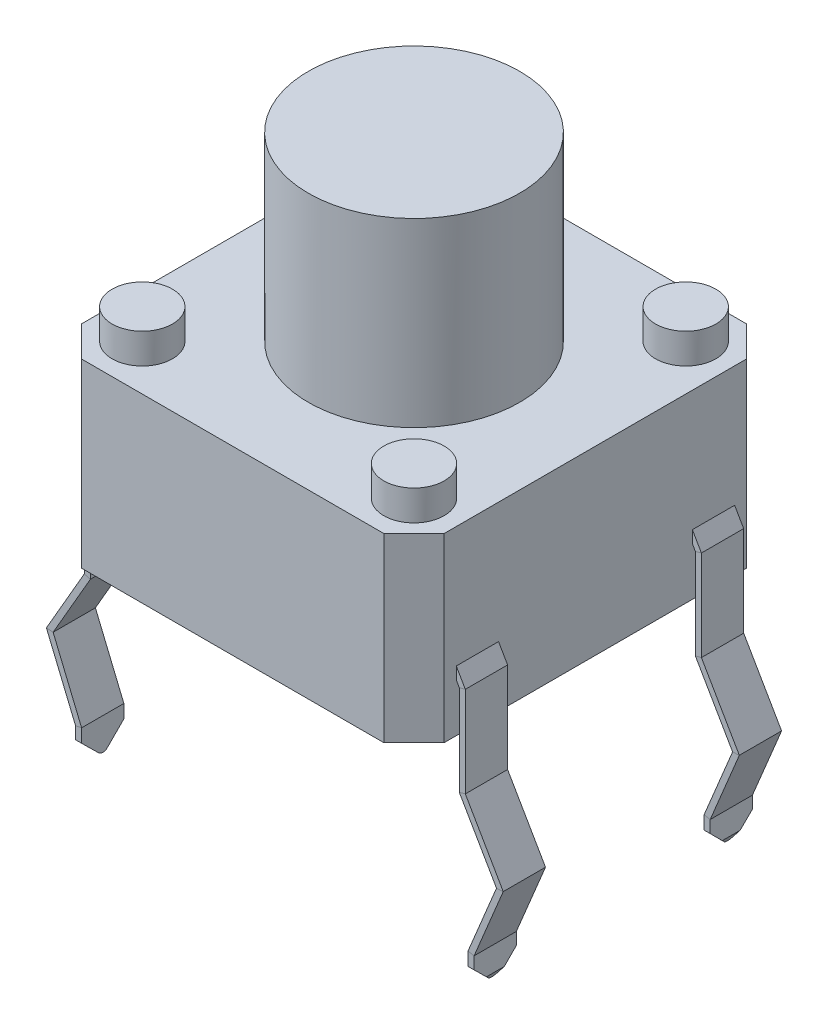
from build123d import *

# Parameters (mm, degrees)
SKETCH1_W               = 6.01
SKETCH1_H               = 6.01
BOSS_EXTRUDE1_DEPTH     = 3
CHAMFER1_SIZE           = 0.5
SKETCH3_R               = 1.75
BOSS_EXTRUDE2_DEPTH     = 3
SKETCH4_R               = 0.5
BOSS_EXTRUDE6_DEPTH     = 0.5
SKETCH5_R               = 0.5
BOSS_EXTRUDE7_DEPTH     = 0.5
SKETCH6_W               = 0.7
SKETCH6_H               = 0.2
MIRROR2_COPY_1_SKETCH_W = 0.7
MIRROR2_COPY_1_SKETCH_H = 0.2
CUT_EXTRUDE1_DEPTH      = 4.782799277


with BuildPart() as part:
    # Sketch1 → Boss-Extrude1 (new body)
    with BuildSketch(Plane(origin=(0, 0, 0), x_dir=(1, 0, 0), z_dir=(0, 1, 0))):
        Rectangle(SKETCH1_W, SKETCH1_H)
    extrude(amount=BOSS_EXTRUDE1_DEPTH)

    # Chamfer1
    chamfer1_edges = [part.edges().sort_by_distance(p)[0] for p in [
        (3.005, 1.5, 3.005),
        (-3.005, 1.5, 3.005),
        (-3.005, 1.5, -3.005),
        (3.005, 1.5, -3.005),
    ]]
    chamfer(chamfer1_edges, length=CHAMFER1_SIZE)

    # Sketch3 → Boss-Extrude2 (add)
    with BuildSketch(Plane(origin=(0, 3, 0), x_dir=(1, 0, 0), z_dir=(0, 1, 0))):
        Circle(SKETCH3_R)
    extrude(amount=BOSS_EXTRUDE2_DEPTH)

    # Sketch4 → Boss-Extrude6 (add)
    with BuildSketch(Plane(origin=(0, 3, 0), x_dir=(1, 0, 0), z_dir=(0, 1, 0))):
        with Locations((2.25, 2.25)):
            Circle(SKETCH4_R)
        with Locations((2.25, -2.25)):
            Circle(SKETCH4_R)
        with Locations((-2.25, 2.25)):
            Circle(SKETCH4_R)
    extrude(amount=BOSS_EXTRUDE6_DEPTH)

    # Sketch5 → Boss-Extrude7 (add)
    with BuildSketch(Plane(origin=(0, 3, 0), x_dir=(1, 0, 0), z_dir=(0, 1, 0))):
        with Locations((-2.25, -2.25)):
            Circle(SKETCH5_R)
    extrude(amount=BOSS_EXTRUDE7_DEPTH)

    # Sweep1: sweep along a path in Sketch7
    with BuildLine(Plane.XY) as sweep1_path:
        Line((-3.005, 0.9), (-3.105, 0.726794919))
        Line((-3.105, 0.726794919), (-3.105, -0.773205081))
        Line((-3.105, -0.773205081), (-3.72715614, -1.850811126))
        Line((-3.72715614, -1.850811126), (-3.25, -3))
        Line((-3.25, -3), (-3.25, -3.5))
    # Sketch6 → Sweep1 (sweep)
    with BuildSketch(Plane.ZY.offset(3.005)):
        with Locations((-1.955, 0.9)):
            Rectangle(SKETCH6_W, SKETCH6_H)
    sweep1 = sweep(path=sweep1_path.line, transition=Transition.RIGHT)

    # Mirror1: Sweep1 across plane
    add(sweep1.mirror(Plane.XY))

    # Mirror2: Sweep1 across plane
    add(sweep1.mirror(Plane(origin=(0, 0, 0), x_dir=(0, 0, 1), z_dir=(1, 0, 0))))

    # Mirror2 copy 1: sweep along a path in Mirror2 copy 1 path
    with BuildLine(Plane(origin=(0, 0, 0), x_dir=(-1, 0, 0), z_dir=(0, 0, -1))) as mirror2_copy_1_path:
        Line((-3.005, 0.9), (-3.105, 0.726794919))
        Line((-3.105, 0.726794919), (-3.105, -0.773205081))
        Line((-3.105, -0.773205081), (-3.72715614, -1.850811126))
        Line((-3.72715614, -1.850811126), (-3.25, -3))
        Line((-3.25, -3), (-3.25, -3.5))
    # Mirror2 copy 1 sketch → Mirror2 copy 1 (sweep)
    with BuildSketch(Plane(origin=(3.005, 0, 0), x_dir=(0, 0, -1), z_dir=(1, 0, 0))):
        with Locations((-1.955, 0.9)):
            Rectangle(MIRROR2_COPY_1_SKETCH_W, MIRROR2_COPY_1_SKETCH_H)
    sweep(path=mirror2_copy_1_path.line, transition=Transition.RIGHT)

    # Sketch8 → Cut-Extrude1 (cut, symmetric)
    with BuildSketch(Plane(origin=(0, 0, 0), x_dir=(0, 0, -1), z_dir=(1, 0, 0))):
        with BuildLine():
            Line((-2.305, -3.211682602), (-2.305, -3.58660254))
            Line((-2.305, -3.58660254), (-1.605, -3.58660254))
            Line((-1.605, -3.58660254), (-1.605, -3.211682602))
            Line((-1.605, -3.211682602), (-1.881694927, -3.48928466))
            ThreePointArc((-1.881694927, -3.48928466), (-1.952077784, -3.518688814), (-2.022718654, -3.489910032))
            Line((-2.022718654, -3.489910032), (-2.305, -3.211682602))
        make_face()
    cut_extrude1 = extrude(amount=CUT_EXTRUDE1_DEPTH, both=True, mode=Mode.SUBTRACT)

    # Mirror3: Cut-Extrude1 across plane
    add(cut_extrude1.mirror(Plane.XY), mode=Mode.SUBTRACT)


solid = part.part
